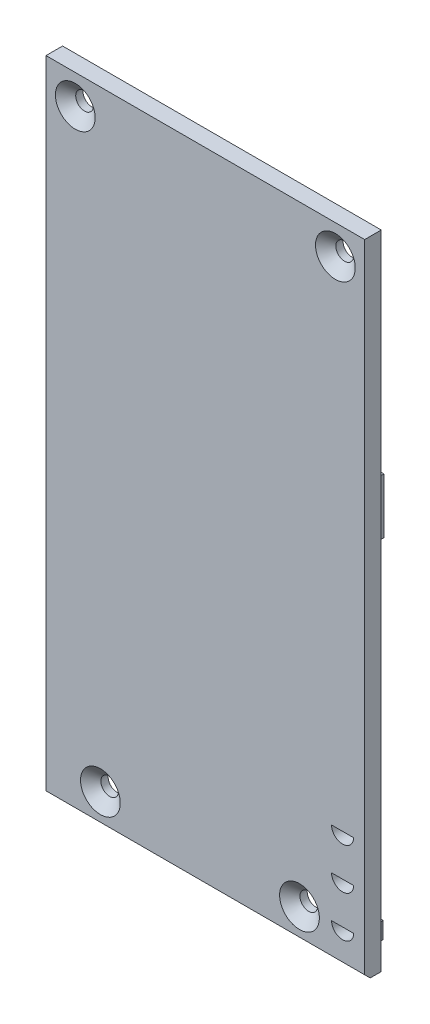
from build123d import *

# Parameters (mm, degrees)
SKETCH1_W            = 57.7
SKETCH1_H            = 114.7
BOSS_EXTRUDE1_DEPTH  = 3
SKETCH2_R            = 1.6
CUT_EXTRUDE1_DEPTH   = 3
CHAMFER1_SIZE        = 2
CHAMFER1_SIZE2       = 1.678199262
SKETCH4_W            = 57.7
SKETCH4_H            = 3
BOSS_EXTRUDE2_DEPTH  = 1.6
SKETCH5_W            = 19
SKETCH5_H            = 6
BOSS_EXTRUDE3_DEPTH  = 2.2
SKETCH7_W            = 19
SKETCH7_H            = 3
BOSS_EXTRUDE4_DEPTH  = 4.5
CHAMFER2_SIZE        = 0.5
SKETCH8_W            = 25.7
SKETCH8_H            = 3
SKETCH8_W_2          = 25
SKETCH8_H_2          = 4
BOSS_EXTRUDE5_DEPTH  = 2
SKETCH9_W            = 25.7
SKETCH9_H            = 7
BOSS_EXTRUDE6_DEPTH  = 4.5
SKETCH10_R           = 2
CUT_EXTRUDE2_DEPTH   = 3
SKETCH11_W           = 4
SKETCH11_H           = 2
BOSS_EXTRUDE7_DEPTH  = 0.7
SKETCH12_W           = 4
SKETCH12_H           = 1.993871031
SKETCH12_H_2         = 2
BOSS_EXTRUDE11_DEPTH = 0.7
SKETCH13_W           = 4.5
SKETCH13_H           = 3
SKETCH13_W_2         = 3
BOSS_EXTRUDE12_DEPTH = 2
SKETCH14_W           = 2.5
SKETCH14_H           = 10
BOSS_EXTRUDE13_DEPTH = 2
CHAMFER3_SIZE        = 1


with BuildPart() as part:
    # Sketch1 → Boss-Extrude1 (new body)
    with BuildSketch(Plane.XY):
        with Locations((28.85, 57.35)):
            Rectangle(SKETCH1_W, SKETCH1_H)
    extrude(amount=BOSS_EXTRUDE1_DEPTH)

    # Sketch2 → Cut-Extrude1 (cut)
    with BuildSketch(Plane.XY.offset(3)):
        with Locations((5.3, 109.4)):
            Circle(SKETCH2_R)
        with Locations((52.4, 109.4)):
            Circle(SKETCH2_R)
        with Locations((9.85, 4.2)):
            Circle(SKETCH2_R)
        with Locations((45.9, 4.2)):
            Circle(SKETCH2_R)
    extrude(amount=-CUT_EXTRUDE1_DEPTH, mode=Mode.SUBTRACT)

    # Chamfer1
    chamfer1_edges = [part.edges().sort_by_distance(p)[0] for p in [
        (3.7, 109.4, 3),
        (44.3, 4.2, 3),
        (8.25, 4.2, 3),
        (50.8, 109.4, 3),
    ]]
    chamfer1_side = [part.faces().sort_by_distance(p)[0] for p in [
        (28.85238123, 57.352686516, 3),
    ]]
    chamfer(chamfer1_edges, length=CHAMFER1_SIZE, length2=CHAMFER1_SIZE2, reference=chamfer1_side[0])

    # Sketch4 → Boss-Extrude2 (add)
    with BuildSketch(Plane.XZ):
        with Locations((28.85, 1.5)):
            Rectangle(SKETCH4_W, SKETCH4_H)
    extrude(amount=BOSS_EXTRUDE2_DEPTH)

    # Sketch5 → Boss-Extrude3 (add)
    with BuildSketch(Plane(origin=(0, 0, 0), x_dir=(-1, 0, 0), z_dir=(0, 0, -1))):
        with Locations((-36.2, 102.2)):
            Rectangle(SKETCH5_W, SKETCH5_H)
    extrude(amount=BOSS_EXTRUDE3_DEPTH)

    # Sketch7 → Boss-Extrude4 (add)
    with BuildSketch(Plane(origin=(0, 0, 0), x_dir=(-1, 0, 0), z_dir=(0, 0, -1))):
        with Locations((-36.2, 105.7)):
            Rectangle(SKETCH7_W, SKETCH7_H)
    extrude(amount=BOSS_EXTRUDE4_DEPTH)

    # Chamfer2
    chamfer2_edges = [part.edges().sort_by_distance(p)[0] for p in [
        (36.2, 104.2, -4.5),
    ]]
    chamfer(chamfer2_edges, length=CHAMFER2_SIZE)

    # Sketch8 → Boss-Extrude5 (add)
    with BuildSketch(Plane(origin=(0, 0, 0), x_dir=(-1, 0, 0), z_dir=(0, 0, -1))):
        with Locations((-26.85, 27.9)):
            Rectangle(SKETCH8_W, SKETCH8_H)
        with Locations((-42.2, 33.4)):
            Rectangle(SKETCH8_W_2, SKETCH8_H_2)
    extrude(amount=BOSS_EXTRUDE5_DEPTH)

    # Sketch9 → Boss-Extrude6 (add)
    with BuildSketch(Plane(origin=(0, 0, 0), x_dir=(-1, 0, 0), z_dir=(0, 0, -1))):
        with Locations((-26.85, 13.9)):
            Rectangle(SKETCH9_W, SKETCH9_H)
    extrude(amount=BOSS_EXTRUDE6_DEPTH)

    # Sketch10 → Cut-Extrude2 (cut)
    with BuildSketch(Plane.XY.offset(3)):
        with Locations((53.7, 19.9)):
            Circle(SKETCH10_R)
        with Locations((53.7, 12.4)):
            Circle(SKETCH10_R)
        with Locations((53.7, 4.9)):
            Circle(SKETCH10_R)
    extrude(amount=-CUT_EXTRUDE2_DEPTH, mode=Mode.SUBTRACT)

    # Sketch11 → Boss-Extrude7 (add)
    with BuildSketch(Plane.XY.offset(3)):
        with Locations((53.7, 20.9)):
            Rectangle(SKETCH11_W, SKETCH11_H)
        with Locations((53.7, 13.4)):
            Rectangle(SKETCH11_W, SKETCH11_H)
        with Locations((53.7, 5.9)):
            Rectangle(SKETCH11_W, SKETCH11_H)
    extrude(amount=-BOSS_EXTRUDE7_DEPTH)

    # Sketch12 → Boss-Extrude11 (add)
    with BuildSketch(Plane(origin=(0, 0, 0), x_dir=(-1, 0, 0), z_dir=(0, 0, -1))):
        with Locations((-53.7, 18.903064484)):
            Rectangle(SKETCH12_W, SKETCH12_H)
        with Locations((-53.7, 11.4)):
            Rectangle(SKETCH12_W, SKETCH12_H_2)
        with Locations((-53.7, 3.9)):
            Rectangle(SKETCH12_W, SKETCH12_H_2)
    extrude(amount=-BOSS_EXTRUDE11_DEPTH)

    # Sketch13 → Boss-Extrude12 (add)
    with BuildSketch(Plane(origin=(0, 0, 0), x_dir=(-1, 0, 0), z_dir=(0, 0, -1))):
        with Locations((-53.8, 3.1)):
            Rectangle(SKETCH13_W, SKETCH13_H)
        with Locations((-3.5, 3.1)):
            Rectangle(SKETCH13_W_2, SKETCH13_H)
    extrude(amount=BOSS_EXTRUDE12_DEPTH)

    # Sketch14 → Boss-Extrude13 (add)
    with BuildSketch(Plane(origin=(0, 0, 0), x_dir=(-1, 0, 0), z_dir=(0, 0, -1))):
        with Locations((-54.95, 69.7)):
            Rectangle(SKETCH14_W, SKETCH14_H)
        with Locations((-26.25, 69.7)):
            Rectangle(SKETCH14_W, SKETCH14_H)
    extrude(amount=BOSS_EXTRUDE13_DEPTH)

    # Chamfer3
    chamfer3_edges = [part.edges().sort_by_distance(p)[0] for p in [
        (28.85, -1.6, 3),
    ]]
    chamfer(chamfer3_edges, length=CHAMFER3_SIZE)


solid = part.part
